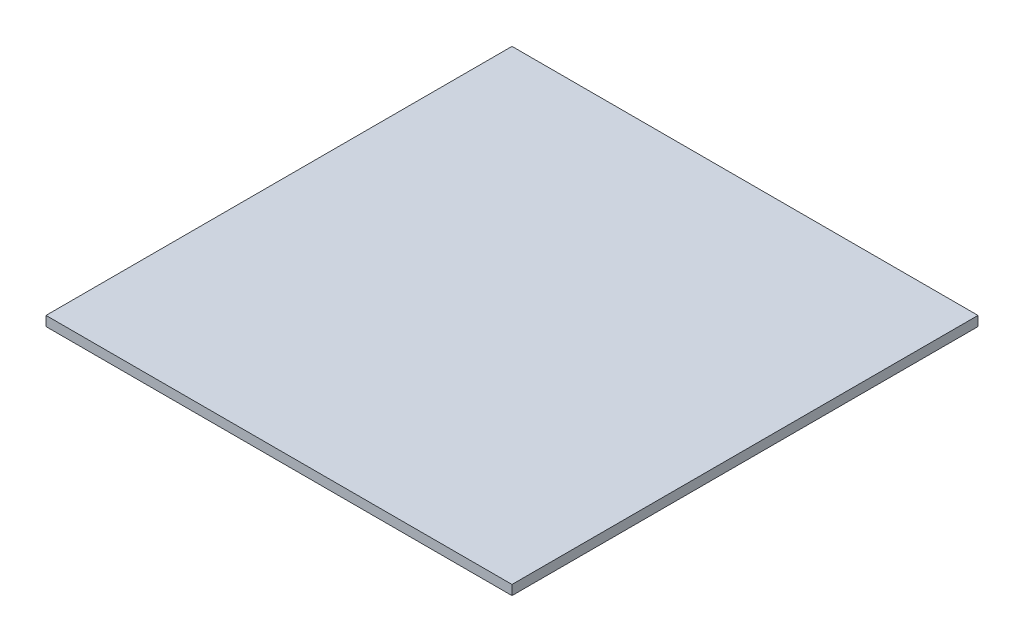
from build123d import *

# Parameters (mm, degrees)
SKETCH1_W           = 304.8
SKETCH1_H           = 304.8
BOSS_EXTRUDE1_DEPTH = 6.35


with BuildPart() as part:
    # Sketch1 → Boss-Extrude1 (new body)
    with BuildSketch(Plane(origin=(0, 0, 0), x_dir=(1, 0, 0), z_dir=(0, 1, 0))):
        Rectangle(SKETCH1_W, SKETCH1_H)
    extrude(amount=BOSS_EXTRUDE1_DEPTH)


solid = part.part
